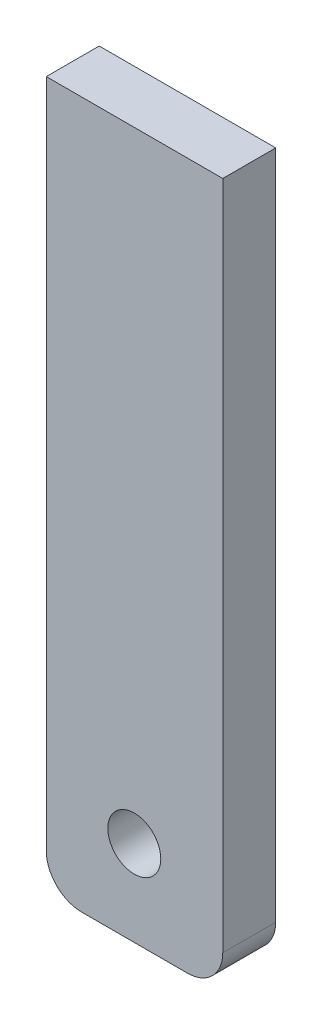
from build123d import *

# Parameters (mm, degrees)
SKETCH1_R           = 1.5
BOSS_EXTRUDE1_DEPTH = 3


with BuildPart() as part:
    # Sketch1 → Boss-Extrude1 (new body)
    with BuildSketch(Plane.XY):
        with BuildLine():
            Line((75.224838359, 1.741579383), (65.224838359, 1.741579383))
            Line((65.224838359, 1.741579383), (65.224838359, -36.258420617))
            ThreePointArc((65.224838359, -36.258420617), (65.810624797, -37.672634179), (67.224838359, -38.258420617))
            Line((67.224838359, -38.258420617), (73.224838359, -38.258420617))
            ThreePointArc((73.224838359, -38.258420617), (74.639051921, -37.672634179), (75.224838359, -36.258420617))
            Line((75.224838359, -36.258420617), (75.224838359, 1.741579383))
        make_face()
        with Locations((70.211902805, -33.405004849)):
            Circle(SKETCH1_R, mode=Mode.SUBTRACT)
    extrude(amount=BOSS_EXTRUDE1_DEPTH)


solid = part.part
